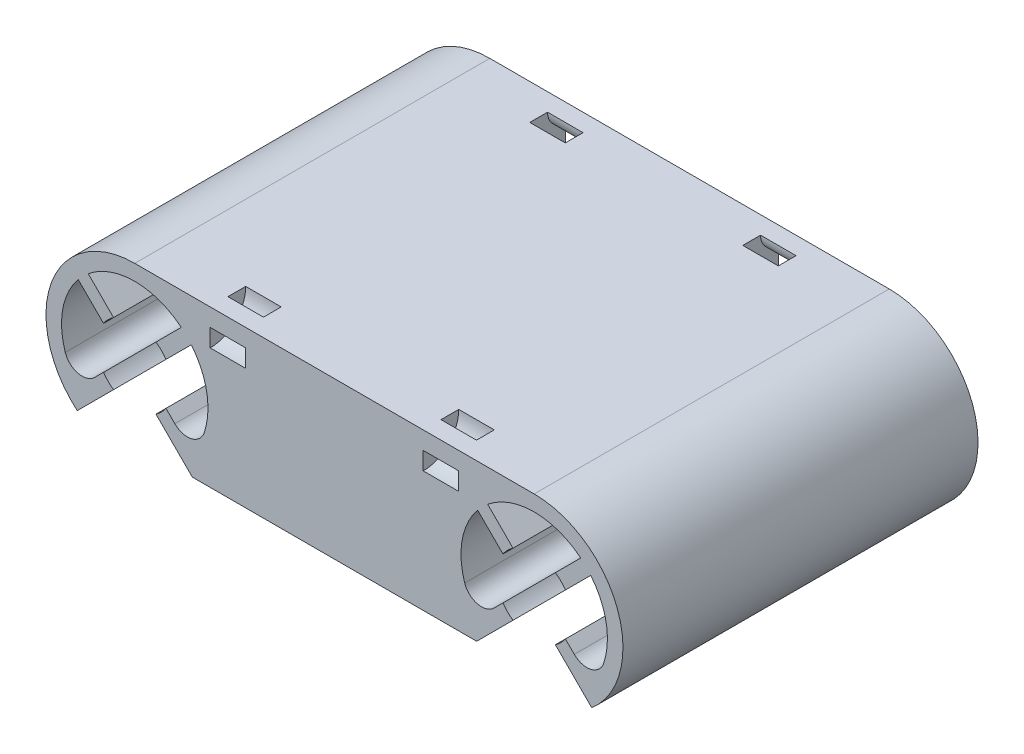
from build123d import *

# Parameters (mm, degrees)
BOSS_EXTRUDE1_DEPTH = 40


with BuildPart() as part:
    # Sketch1 → Boss-Extrude1 (new body)
    with BuildSketch(Plane.XY):
        with BuildLine():
            Line((-18.982831897, 2.385797253), (-16.128175583, 5.240453568))
            ThreePointArc((-16.128175583, 5.240453568), (-14.388813512, 1.507034758), (-14.671071516, -2.601995157))
            ThreePointArc((-14.671071516, -2.601995157), (-16.108631881, -3.917504194), (-17.983207135, -3.385422015))
            Line((-17.983207135, -3.385422015), (-18.982831897, -2.385797253))
            ThreePointArc((-18.982831897, -2.385797253), (-19.49479618, -3.00520382), (-20.114202747, -3.517168103))
            Line((-20.114202747, -3.517168103), (-16.01728135, -7.6140895))
            Line((-16.01728135, -7.6140895), (16.01728135, -7.6140895))
            Line((16.01728135, -7.6140895), (20.114202747, -3.517168103))
            ThreePointArc((20.114202747, -3.517168103), (19.49479618, -3.00520382), (18.982831897, -2.385797253))
            Line((18.982831897, -2.385797253), (17.983207135, -3.385422015))
            ThreePointArc((17.983207135, -3.385422015), (16.108631881, -3.917504194), (14.671071516, -2.601995157))
            ThreePointArc((14.671071516, -2.601995157), (14.388813512, 1.507034758), (16.128175583, 5.240453568))
            Line((16.128175583, 5.240453568), (18.982831897, 2.385797253))
            ThreePointArc((18.982831897, 2.385797253), (19.49479618, 3.00520382), (20.114202747, 3.517168103))
            Line((20.114202747, 3.517168103), (17.259546432, 6.371824417))
            ThreePointArc((17.259546432, 6.371824417), (22.5, 8.25), (27.740453568, 6.371824417))
            Line((27.740453568, 6.371824417), (24.885797253, 3.517168103))
            ThreePointArc((24.885797253, 3.517168103), (25.50520382, 3.00520382), (26.017168103, 2.385797253))
            Line((26.017168103, 2.385797253), (28.871824417, 5.240453568))
            ThreePointArc((28.871824417, 5.240453568), (30.611186488, 1.507034758), (30.328928484, -2.601995157))
            ThreePointArc((30.328928484, -2.601995157), (28.891368119, -3.917504194), (27.016792865, -3.385422015))
            Line((27.016792865, -3.385422015), (26.017168103, -2.385797253))
            ThreePointArc((26.017168103, -2.385797253), (25.50520382, -3.00520382), (24.885797253, -3.517168103))
            Line((24.885797253, -3.517168103), (28.98271865, -7.6140895))
            ThreePointArc((28.98271865, -7.6140895), (31.884585633, 3.453918427), (22.5, 10))
            Line((22.5, 10), (-22.5, 10))
            ThreePointArc((-22.5, 10), (-31.884585633, 3.453918427), (-28.98271865, -7.6140895))
            Line((-28.98271865, -7.6140895), (-24.885797253, -3.517168103))
            ThreePointArc((-24.885797253, -3.517168103), (-25.50520382, -3.00520382), (-26.017168103, -2.385797253))
            Line((-26.017168103, -2.385797253), (-27.016792865, -3.385422015))
            ThreePointArc((-27.016792865, -3.385422015), (-28.891368119, -3.917504194), (-30.328928484, -2.601995157))
            ThreePointArc((-30.328928484, -2.601995157), (-30.611186488, 1.507034758), (-28.871824417, 5.240453568))
            Line((-28.871824417, 5.240453568), (-26.017168103, 2.385797253))
            ThreePointArc((-26.017168103, 2.385797253), (-25.50520382, 3.00520382), (-24.885797253, 3.517168103))
            Line((-24.885797253, 3.517168103), (-27.740453568, 6.371824417))
            ThreePointArc((-27.740453568, 6.371824417), (-22.5, 8.25), (-17.259546432, 6.371824417))
            Line((-17.259546432, 6.371824417), (-20.114202747, 3.517168103))
            ThreePointArc((-20.114202747, 3.517168103), (-19.49479618, 3.00520382), (-18.982831897, 2.385797253))
        make_face()
    extrude(amount=BOSS_EXTRUDE1_DEPTH)

    # Sketch3 → Cut-Revolve1 (revolve, cut)
    with BuildSketch(Plane.XY.offset(40)):
        Polygon((12, 8), (10, 8), (10, 6), (14, 6), (14, 8), align=None)
        Polygon((-14, 8), (-12, 8), (-10, 8), (-10, 6), (-14, 6), align=None)
    cut_revolve1 = revolve(axis=Axis((-22.5, 10, 40), (-1, 0, 0)), mode=Mode.SUBTRACT)

    # Mirror1: Cut-Revolve1 across plane
    add(cut_revolve1.mirror(Plane.XY.offset(20)), mode=Mode.SUBTRACT)


solid = part.part
